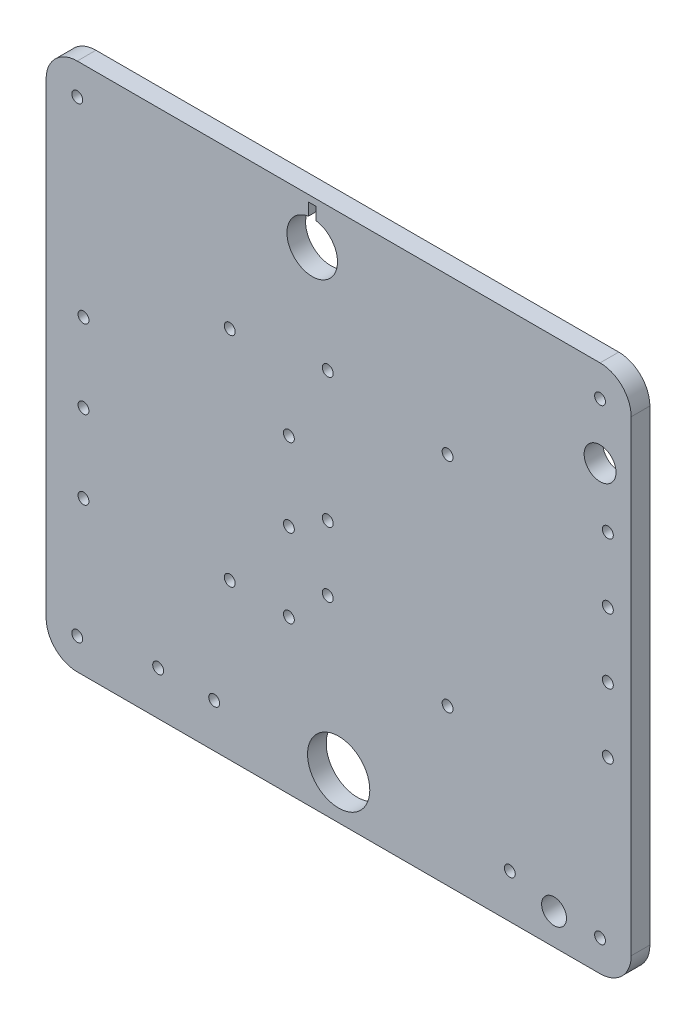
from build123d import *

# Parameters (mm, degrees)
ESQUISSE1_R        = 1.75
ESQUISSE1_R_2      = 10
ESQUISSE1_R_3      = 5.125
ESQUISSE1_R_4      = 4
BOSS_EXTRU_1_DEPTH = 6


with BuildPart() as part:
    # Esquisse1 → Boss.-Extru.1 (new body)
    with BuildSketch(Plane.XY):
        with BuildLine():
            Line((-94, -75), (-94, 75))
            ThreePointArc((-94, 75), (-91.071067812, 82.071067812), (-84, 85))
            Line((-84, 85), (84, 85))
            ThreePointArc((84, 85), (91.071067812, 82.071067812), (94, 75))
            Line((94, 75), (94, -75))
            ThreePointArc((94, -75), (91.071067812, -82.071067812), (84, -85))
            Line((84, -85), (-84, -85))
            ThreePointArc((-84, -85), (-91.071067812, -82.071067812), (-94, -75))
        make_face()
        with Locations((-84, 75)):
            Circle(ESQUISSE1_R, mode=Mode.SUBTRACT)
        with Locations((84, 75)):
            Circle(ESQUISSE1_R, mode=Mode.SUBTRACT)
        with Locations((84, -75)):
            Circle(ESQUISSE1_R, mode=Mode.SUBTRACT)
        with Locations((-84, -75)):
            Circle(ESQUISSE1_R, mode=Mode.SUBTRACT)
        with Locations((-82, -35.7)):
            Circle(ESQUISSE1_R, mode=Mode.SUBTRACT)
        with Locations((-82, -10.5)):
            Circle(ESQUISSE1_R, mode=Mode.SUBTRACT)
        with Locations((-82, 14.7)):
            Circle(ESQUISSE1_R, mode=Mode.SUBTRACT)
        with Locations((-16, -35.7)):
            Circle(ESQUISSE1_R, mode=Mode.SUBTRACT)
        with Locations((-3.5, -23.5)):
            Circle(ESQUISSE1_R, mode=Mode.SUBTRACT)
        with Locations((86.5, -23.5)):
            Circle(ESQUISSE1_R, mode=Mode.SUBTRACT)
        with Locations((86.5, -2.625)):
            Circle(ESQUISSE1_R, mode=Mode.SUBTRACT)
        with Locations((86.5, 18.25)):
            Circle(ESQUISSE1_R, mode=Mode.SUBTRACT)
        with Locations((86.5, 39.125)):
            Circle(ESQUISSE1_R, mode=Mode.SUBTRACT)
        with Locations((-3.5, -2.625)):
            Circle(ESQUISSE1_R, mode=Mode.SUBTRACT)
        with Locations((-3.5, 39.125)):
            Circle(ESQUISSE1_R, mode=Mode.SUBTRACT)
        with Locations((-16, -10.5)):
            Circle(ESQUISSE1_R, mode=Mode.SUBTRACT)
        with Locations((-16, 14.7)):
            Circle(ESQUISSE1_R, mode=Mode.SUBTRACT)
        with Locations((-58, -70.9)):
            Circle(ESQUISSE1_R, mode=Mode.SUBTRACT)
        with Locations((-40, -70.9)):
            Circle(ESQUISSE1_R, mode=Mode.SUBTRACT)
        with Locations((55, -70.9)):
            Circle(ESQUISSE1_R, mode=Mode.SUBTRACT)
        with Locations((-35, 35)):
            Circle(ESQUISSE1_R, mode=Mode.SUBTRACT)
        with Locations((35, 35)):
            Circle(ESQUISSE1_R, mode=Mode.SUBTRACT)
        with Locations((35, -35)):
            Circle(ESQUISSE1_R, mode=Mode.SUBTRACT)
        with Locations((-35, -35)):
            Circle(ESQUISSE1_R, mode=Mode.SUBTRACT)
        with Locations((0, -70.9)):
            Circle(ESQUISSE1_R_2, mode=Mode.SUBTRACT)
        with Locations((84, 57.0625)):
            Circle(ESQUISSE1_R_3, mode=Mode.SUBTRACT)
        with Locations((69.210172414, -75)):
            Circle(ESQUISSE1_R_4, mode=Mode.SUBTRACT)
        with BuildLine():
            Line((-9.75, 78.928270362), (-9.75, 82.928270362))
            Line((-9.75, 82.928270362), (-7.25, 82.928270362))
            Line((-7.25, 82.928270362), (-7.25, 78.928270362))
            ThreePointArc((-7.25, 78.928270362), (-8.5, 62.775), (-9.75, 78.928270362))
        make_face(mode=Mode.SUBTRACT)
    extrude(amount=BOSS_EXTRU_1_DEPTH)


solid = part.part
